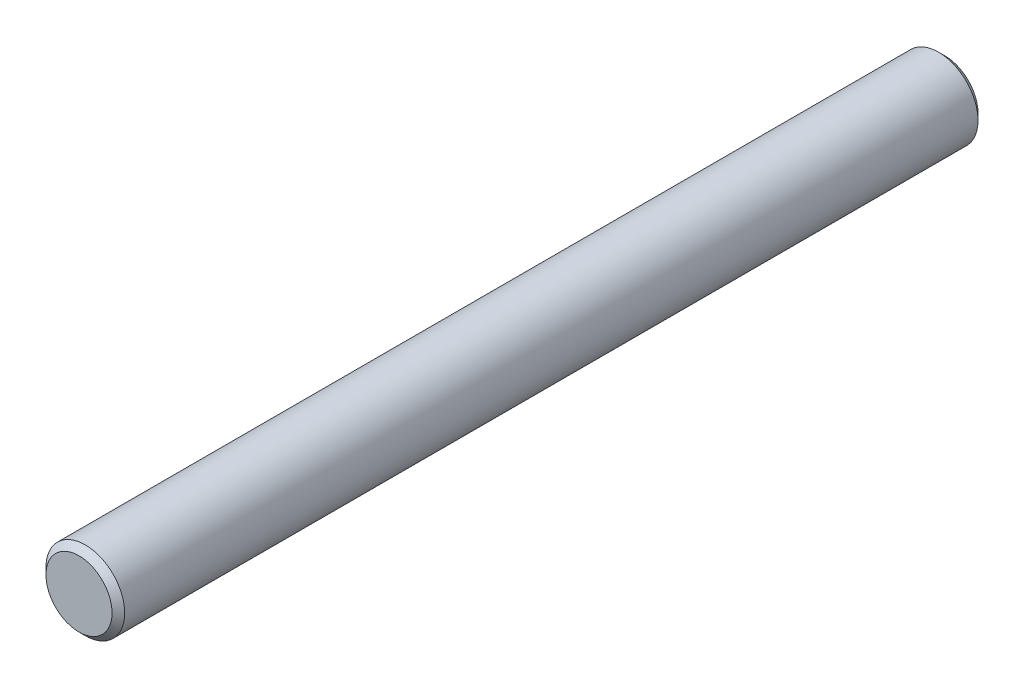
from build123d import *

# Parameters (mm, degrees)
SKETCH2_R           = 1.25
BOSS_EXTRUDE1_DEPTH = 13.75
CHAMFER1_SIZE       = 0.2


with BuildPart() as part:
    # Sketch2 → Boss-Extrude1 (new body, symmetric)
    with BuildSketch(Plane.XY):
        Circle(SKETCH2_R)
    extrude(amount=BOSS_EXTRUDE1_DEPTH, both=True)

    # Chamfer1
    chamfer1_edges = [part.edges().sort_by_distance(p)[0] for p in [
        (-1.25, 0, -13.75),
        (-1.25, 0, 13.75),
    ]]
    chamfer(chamfer1_edges, length=CHAMFER1_SIZE)


solid = part.part
